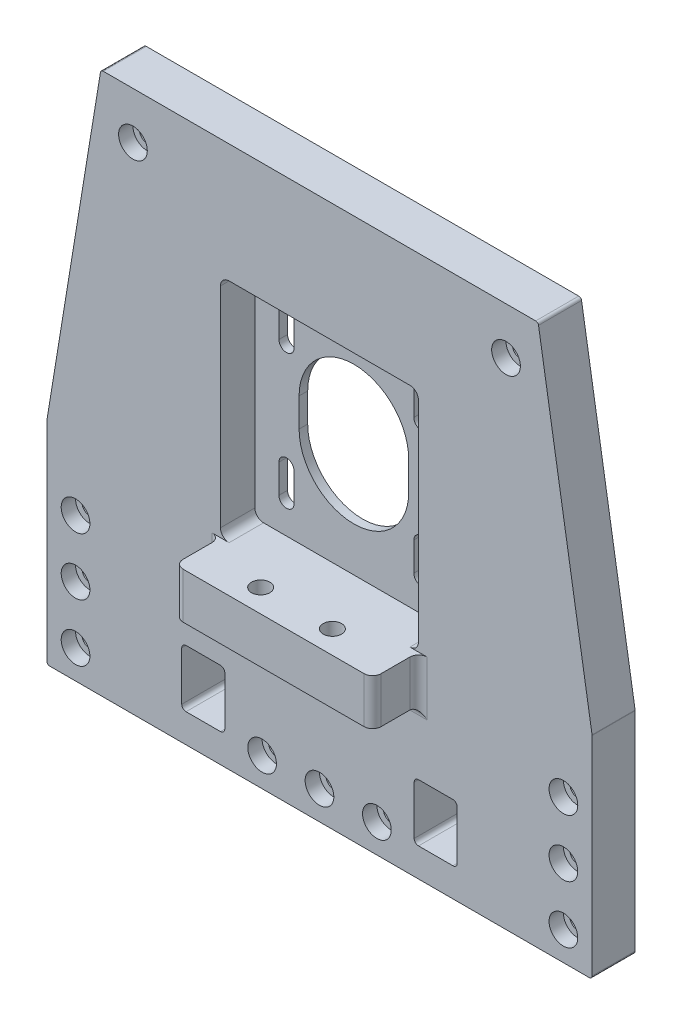
from build123d import *

# Parameters (mm, degrees)
PANEL_SKETCH_W                                = 15
PANEL_SKETCH_H                                = 20
PLATE_EXTRUSION_DEPTH                         = 15
EXTERNAL_EDGE_FILLET_R                        = 1
INTERNAL_EDGE_FILLET_R                        = 1.5
CBORE_FOR_M5_SHCS2_D                          = 5.5
CBORE_FOR_M5_SHCS2_CBORE_D                    = 10
CBORE_FOR_M5_SHCS2_CBORE_DEPTH                = 5
F_8_0MM_DOWEL_HOLE1_D                         = 8
STEPPER_CENTERING_HOLE_CUT_EXTRUDE_DEPTH      = 16
STEPPER_RECESS_CUT_EXTRUDE_DEPTH              = 12
FILLET2_R                                     = 3
Y_DRIVE_SKETCH_6_W                            = 69
Y_DRIVE_SKETCH_6_H                            = 16
BOSS_EXTRUDE2_DEPTH                           = 16
M5_CLEARANCE_HOLE2_D                          = 5.3
F_6_5MM_M5_FLANGED_HEAT_SET_INSERT_HOLE_D     = 6.4
F_6_5MM_M5_FLANGED_HEAT_SET_INSERT_HOLE_DEPTH = 10
F_6_5MM_M5_FLANGED_HEAT_SET_INSERT_HOLE_TIP   = 1.922753981
FILLET5_R                                     = 3
FILLET4_R                                     = 3


with BuildPart() as part:
    # Panel Sketch → Plate Extrusion (new body)
    with BuildSketch(Plane.XY):
        Polygon((-95, 47.162025), (-95, -26.5), (95, -26.5), (95, 47.162025), (76.1938, 162.35), (-76.1938, 162.35), align=None)
        with Locations((-40.5, -6.5)):
            Rectangle(PANEL_SKETCH_W, PANEL_SKETCH_H, mode=Mode.SUBTRACT)
        with Locations((40.5, -6.5)):
            Rectangle(PANEL_SKETCH_W, PANEL_SKETCH_H, mode=Mode.SUBTRACT)
    extrude(amount=-PLATE_EXTRUSION_DEPTH)

    # External Edge Fillet
    external_edge_fillet_edges = [part.edges().sort_by_distance(p)[0] for p in [
        (95, -26.5, -7.5),
        (-95, -26.5, -7.5),
        (-95, 47.162025, -7.5),
        (-76.1938, 162.35, -7.5),
        (76.1938, 162.35, -7.5),
        (95, 47.162025, -7.5),
    ]]
    fillet(external_edge_fillet_edges, radius=EXTERNAL_EDGE_FILLET_R)

    # Internal Edge Fillet
    internal_edge_fillet_edges = [part.edges().sort_by_distance(p)[0] for p in [
        (48, 3.5, -7.5),
        (33, 3.5, -7.5),
        (33, -16.5, -7.5),
        (48, -16.5, -7.5),
        (-33, 3.5, -7.5),
        (-48, 3.5, -7.5),
        (-48, -16.5, -7.5),
        (-33, -16.5, -7.5),
    ]]
    fillet(internal_edge_fillet_edges, radius=INTERNAL_EDGE_FILLET_R)

    # CBORE for M5 SHCS2 (through all)
    with Locations(Plane.XY):
        with Locations((-85, 23.5), (-85, 3.5), (-85, -16.5), (-20, -16.5), (0, -16.5), (20, -16.5), (85, -16.5), (85, 3.5), (85, 23.5), (-65, 146), (65, 146)):
            CounterBoreHole(CBORE_FOR_M5_SHCS2_D / 2, CBORE_FOR_M5_SHCS2_CBORE_D / 2, CBORE_FOR_M5_SHCS2_CBORE_DEPTH)

    # 8.0mm Dowel Hole1 (through all)
    with Locations(Plane.XY):
        with Locations((0, 16.5)):
            Hole(F_8_0MM_DOWEL_HOLE1_D / 2)

    # Y Drive Sketch → Stepper Centering Hole Cut-Extrude (cut, through all)
    with BuildSketch(Plane.XY):
        with BuildLine():
            Line((-26.125, 100), (-26.125, 110))
            ThreePointArc((-26.125, 110), (-23.5, 112.625), (-20.875, 110))
            Line((-20.875, 110), (-20.875, 100))
            ThreePointArc((-20.875, 100), (-23.5, 97.375), (-26.125, 100))
        make_face()
        with BuildLine():
            Line((20.875, 100), (20.875, 110))
            ThreePointArc((20.875, 110), (23.5, 112.625), (26.125, 110))
            Line((26.125, 110), (26.125, 100))
            ThreePointArc((26.125, 100), (23.5, 97.375), (20.875, 100))
        make_face()
        with BuildLine():
            Line((20.875, 53), (20.875, 63))
            ThreePointArc((20.875, 63), (23.5, 65.625), (26.125, 63))
            Line((26.125, 63), (26.125, 53))
            ThreePointArc((26.125, 53), (23.5, 50.375), (20.875, 53))
        make_face()
        with BuildLine():
            Line((-26.125, 53), (-26.125, 63))
            ThreePointArc((-26.125, 63), (-23.5, 65.625), (-20.875, 63))
            Line((-20.875, 63), (-20.875, 53))
            ThreePointArc((-20.875, 53), (-23.5, 50.375), (-26.125, 53))
        make_face()
        with BuildLine():
            Line((-19.1, 76.5), (-19.1, 86.5))
            ThreePointArc((-19.1, 86.5), (0, 105.6), (19.1, 86.5))
            Line((19.1, 86.5), (19.1, 76.5))
            ThreePointArc((19.1, 76.5), (0, 57.4), (-19.1, 76.5))
        make_face()
    extrude(amount=-STEPPER_CENTERING_HOLE_CUT_EXTRUDE_DEPTH, mode=Mode.SUBTRACT)

    # Y Drive Sketch_3 → Stepper Recess Cut-Extrude (cut)
    with BuildSketch(Plane.XY):
        Polygon((-34.5, 121), (-34.5, 111), (-34.5, 42), (34.5, 42), (34.5, 111), (34.5, 121), align=None)
        with BuildLine():
            ThreePointArc((-20.875, 53), (-23.5, 50.375), (-26.125, 53))
            Line((-26.125, 53), (-26.125, 63))
            ThreePointArc((-26.125, 63), (-23.5, 65.625), (-20.875, 63))
            Line((-20.875, 63), (-20.875, 53))
        make_face(mode=Mode.SUBTRACT)
        with BuildLine():
            ThreePointArc((26.125, 53), (23.5, 50.375), (20.875, 53))
            Line((20.875, 53), (20.875, 63))
            ThreePointArc((20.875, 63), (23.5, 65.625), (26.125, 63))
            Line((26.125, 63), (26.125, 53))
        make_face(mode=Mode.SUBTRACT)
        with BuildLine():
            ThreePointArc((19.1, 76.5), (0, 57.4), (-19.1, 76.5))
            Line((-19.1, 76.5), (-19.1, 86.5))
            ThreePointArc((-19.1, 86.5), (0, 105.6), (19.1, 86.5))
            Line((19.1, 86.5), (19.1, 76.5))
        make_face(mode=Mode.SUBTRACT)
        with BuildLine():
            ThreePointArc((-20.875, 100), (-23.5, 97.375), (-26.125, 100))
            Line((-26.125, 100), (-26.125, 110))
            ThreePointArc((-26.125, 110), (-23.5, 112.625), (-20.875, 110))
            Line((-20.875, 110), (-20.875, 100))
        make_face(mode=Mode.SUBTRACT)
        with BuildLine():
            ThreePointArc((26.125, 100), (23.5, 97.375), (20.875, 100))
            Line((20.875, 100), (20.875, 110))
            ThreePointArc((20.875, 110), (23.5, 112.625), (26.125, 110))
            Line((26.125, 110), (26.125, 100))
        make_face(mode=Mode.SUBTRACT)
    extrude(amount=-STEPPER_RECESS_CUT_EXTRUDE_DEPTH, mode=Mode.SUBTRACT)

    # Fillet2
    fillet2_edges = [part.edges().sort_by_distance(p)[0] for p in [
        (-34.5, 121, -6),
        (34.5, 121, -6),
        (34.5, 42, -6),
        (-34.5, 42, -6),
    ]]
    fillet(fillet2_edges, radius=FILLET2_R)

    # Y Drive Sketch_6 → Boss-Extrude2 (add)
    with BuildSketch(Plane.XY):
        with Locations((0, 34)):
            Rectangle(Y_DRIVE_SKETCH_6_W, Y_DRIVE_SKETCH_6_H)
    extrude(amount=BOSS_EXTRUDE2_DEPTH)

    # M5 Clearance Hole2 (through all)
    with Locations(Plane(origin=(0, 26, 0), x_dir=(-1, 0, 0), z_dir=(0, -1, 0))):
        with Locations((12.5, -8), (-12.5, -8)):
            Hole(M5_CLEARANCE_HOLE2_D / 2)

    # 6.5mm M5 Flanged Heat Set Insert Hole
    with Locations(Plane(origin=(0, 42, 0), x_dir=(1, 0, 0), z_dir=(0, 1, 0))):
        with Locations((-12.5, -8), (12.5, -8)):
            Hole(F_6_5MM_M5_FLANGED_HEAT_SET_INSERT_HOLE_D / 2, depth=F_6_5MM_M5_FLANGED_HEAT_SET_INSERT_HOLE_DEPTH)
            with Locations((0, 0, -(F_6_5MM_M5_FLANGED_HEAT_SET_INSERT_HOLE_DEPTH + F_6_5MM_M5_FLANGED_HEAT_SET_INSERT_HOLE_TIP / 2))):  # 118° drill point
                Cone(0, F_6_5MM_M5_FLANGED_HEAT_SET_INSERT_HOLE_D / 2, F_6_5MM_M5_FLANGED_HEAT_SET_INSERT_HOLE_TIP, mode=Mode.SUBTRACT)

    # Fillet5
    fillet5_edges = [part.edges().sort_by_distance(p)[0] for p in [
        (-34.5, 34, 16),
        (34.5, 34, 16),
    ]]
    fillet(fillet5_edges, radius=FILLET5_R)

    # Fillet4
    fillet4_edges = [part.edges().sort_by_distance(p)[0] for p in [
        (-34.5, 34, 0),
        (0, 26, 0),
        (34.5, 34, 0),
    ]]
    fillet(fillet4_edges, radius=FILLET4_R)


solid = part.part
